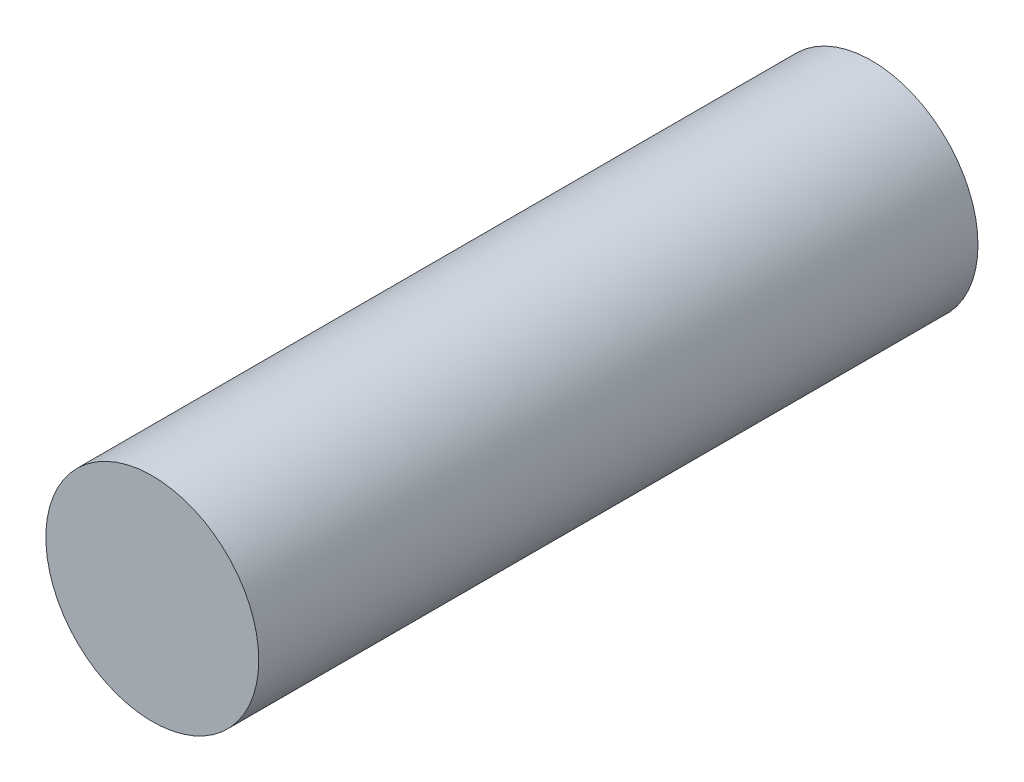
from build123d import *

# Parameters (mm, degrees)
SKETCH1_R           = 7.4
BOSS_EXTRUDE1_DEPTH = 25


with BuildPart() as part:
    # Sketch1 → Boss-Extrude1 (new body, symmetric)
    with BuildSketch(Plane.XY):
        Circle(SKETCH1_R)
    extrude(amount=BOSS_EXTRUDE1_DEPTH, both=True)


solid = part.part
